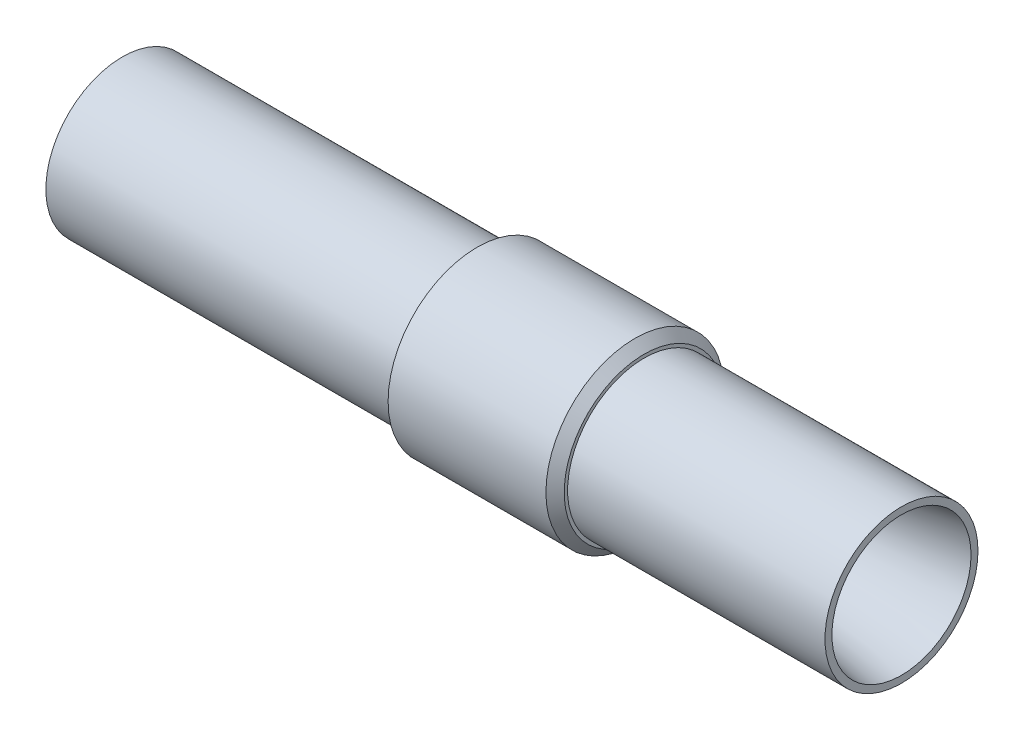
from build123d import *

# Parameters (mm, degrees)
SKETCH_2_R      = 32
SKETCH_2_R_2    = 27.5
EXTRUDE_1_DEPTH = 60
CHAMFER_1_SIZE  = 3.2875


with BuildPart() as part:
    # Эскиз1 → Повернуть1 (revolve)
    with BuildSketch(Plane.XY):
        Polygon((0, 27.5), (-280, 27.5), (-280, 25), (-145, 12.5), (-77.5, 12.5), (0, 25), align=None)
    revolve(axis=Axis((0, 0, 0), (-1, 0, 0)))

    # Эскиз2 → Бобышка-Вытянуть1 (add)
    with BuildSketch(Plane(origin=(-152.5, 0, 0), x_dir=(0, 0, -1), z_dir=(1, 0, 0))):
        Circle(SKETCH_2_R)
        Circle(SKETCH_2_R_2, mode=Mode.SUBTRACT)
    extrude(amount=EXTRUDE_1_DEPTH)

    # Фаска1
    chamfer_1_edges = [part.edges().sort_by_distance(p)[0] for p in [
        (-92.5, 0, 32),
    ]]
    chamfer(chamfer_1_edges, length=CHAMFER_1_SIZE)


solid = part.part
